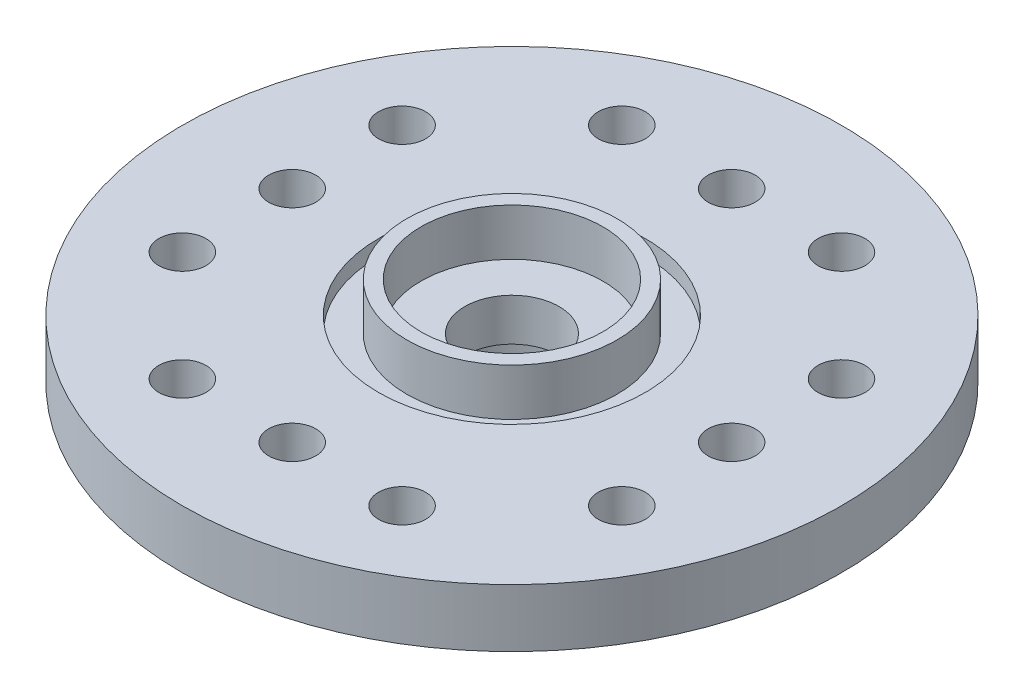
from build123d import *

# Parameters (mm, degrees)
SKETCH1_R           = 10.5
BOSS_EXTRUDE1_DEPTH = 1.85
SKETCH2_R           = 4.25
CUT_EXTRUDE1_DEPTH  = 0.5
SKETCH3_R           = 3.35
SKETCH3_R_2         = 2.9
BOSS_EXTRUDE2_DEPTH = 1.5
SKETCH4_R           = 4.5
SKETCH4_R_2         = 2.75
BOSS_EXTRUDE3_DEPTH = 3.5
SKETCH5_R           = 1.5
CUT_EXTRUDE2_DEPTH  = 5.85
SKETCH6_R           = 0.75
CUT_EXTRUDE3_DEPTH  = 6.35
CIRPATTERN1_COUNT   = 4


with BuildPart() as part:
    # Sketch1 → Boss-Extrude1 (new body)
    with BuildSketch(Plane(origin=(0, 0, 0), x_dir=(1, 0, 0), z_dir=(0, 1, 0))):
        Circle(SKETCH1_R)
    extrude(amount=BOSS_EXTRUDE1_DEPTH)

    # Sketch2 → Cut-Extrude1 (cut)
    with BuildSketch(Plane(origin=(0, 1.85, 0), x_dir=(1, 0, 0), z_dir=(0, 1, 0))):
        Circle(SKETCH2_R)
    extrude(amount=-CUT_EXTRUDE1_DEPTH, mode=Mode.SUBTRACT)

    # Sketch3 → Boss-Extrude2 (add)
    with BuildSketch(Plane(origin=(0, 1.35, 0), x_dir=(1, 0, 0), z_dir=(0, 1, 0))):
        Circle(SKETCH3_R)
        Circle(SKETCH3_R_2, mode=Mode.SUBTRACT)
    extrude(amount=BOSS_EXTRUDE2_DEPTH)

    # Sketch4 → Boss-Extrude3 (add)
    with BuildSketch(Plane.XZ):
        Circle(SKETCH4_R)
        Circle(SKETCH4_R_2, mode=Mode.SUBTRACT)
    extrude(amount=BOSS_EXTRUDE3_DEPTH)

    # Sketch5 → Cut-Extrude2 (cut, through all)
    with BuildSketch(Plane(origin=(0, 1.35, 0), x_dir=(1, 0, 0), z_dir=(0, 1, 0))):
        Circle(SKETCH5_R)
    extrude(amount=-CUT_EXTRUDE2_DEPTH, mode=Mode.SUBTRACT)

    # Sketch6 → Cut-Extrude3 (cut, through all)
    with BuildSketch(Plane(origin=(0, 1.85, 0), x_dir=(1, 0, 0), z_dir=(0, 1, 0))):
        with Locations((-3.5, 7)):
            Circle(SKETCH6_R)
        with Locations((0, 7)):
            Circle(SKETCH6_R)
        with Locations((3.5, 7)):
            Circle(SKETCH6_R)
    cut_extrude3 = extrude(amount=-CUT_EXTRUDE3_DEPTH, mode=Mode.SUBTRACT)

    # CirPattern1: Cut-Extrude3 ×4 about axis
    cirpattern1_axis = Axis((0, 0, 0), (0, 1, 0))
    for i in range(1, CIRPATTERN1_COUNT):
        add(cut_extrude3.rotate(cirpattern1_axis, i * 360 / CIRPATTERN1_COUNT), mode=Mode.SUBTRACT)


solid = part.part
